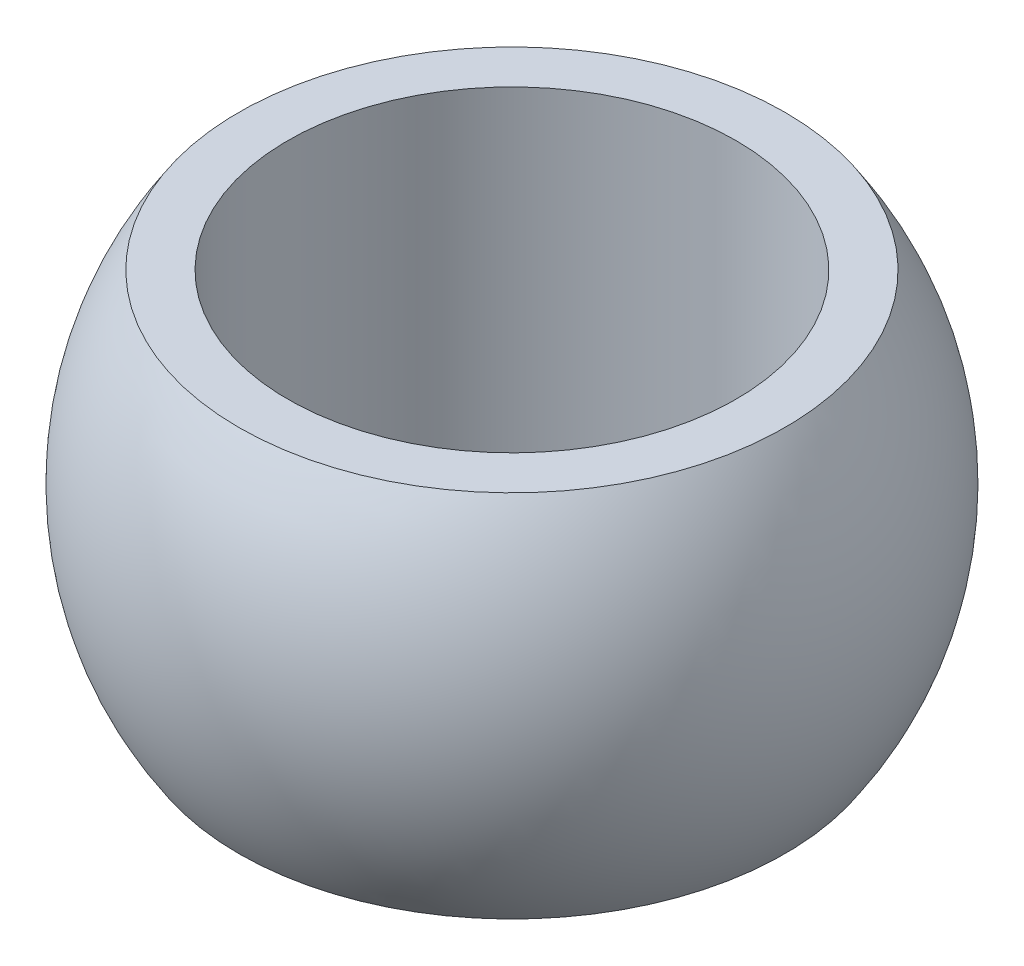
from build123d import *


with BuildPart() as part:
    # Esquisse1 → Révolution1 (revolve)
    with BuildSketch(Plane.XY):
        with BuildLine():
            Line((8.5, -7), (10.356157589, -7))
            ThreePointArc((10.356157589, -7), (12.5, 0), (10.356157589, 7))
            Line((10.356157589, 7), (8.5, 7))
            Line((8.5, 7), (8.5, -7))
        make_face()
    revolve(axis=Axis((0, -15.339775559, 0), (0, 1, 0)))


solid = part.part
